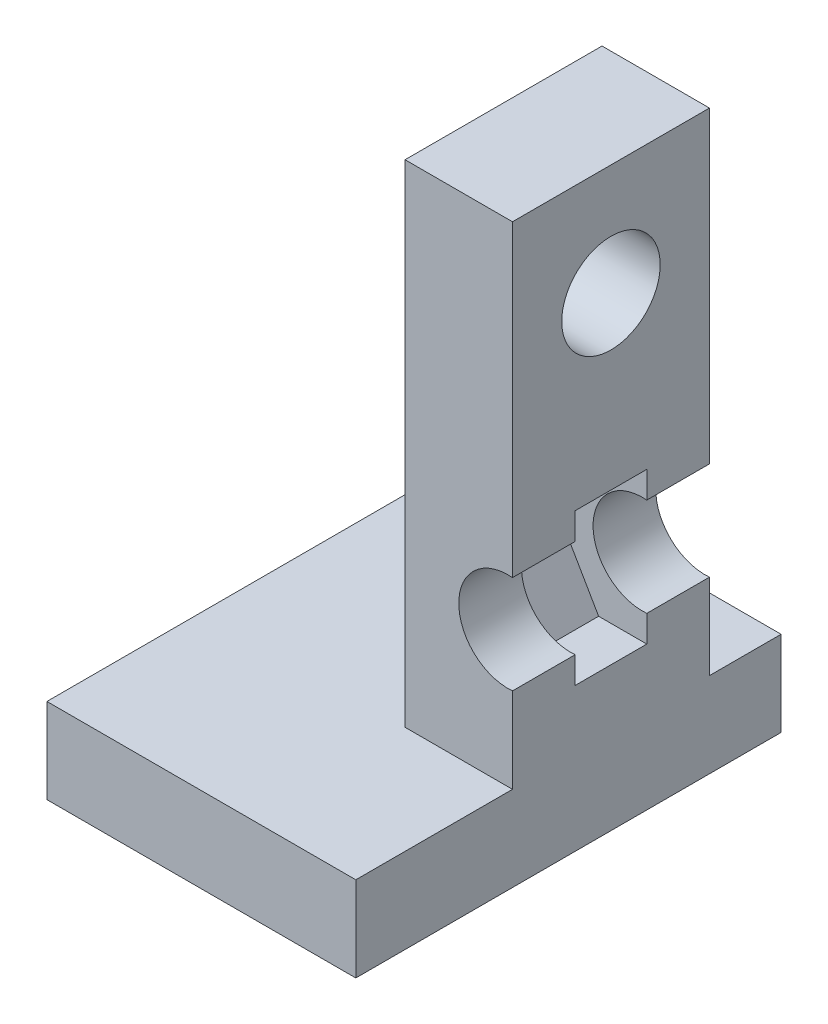
from build123d import *

# Parameters (mm, degrees)
SKETCH_1_W          = 23
SKETCH_1_H          = 64.4
EXTRUDE_1_DEPTH     = 8
SKETCH_3_W          = 23
SKETCH_3_H          = 64.4
SKETCH_3_R          = 5.5
EXTRUDE_2_DEPTH     = 7
SKETCH_4_W          = 23
SKETCH_4_H          = 64.4
SKETCH_4_R          = 5.5
EXTRUDE_3_DEPTH     = 7
SKETCH_5_R          = 5.5
CUT_EXTRUDE_1_DEPTH = 24
SKETCH_6_W          = 22
SKETCH_6_H          = 64.4
CUT_EXTRUDE_2_DEPTH = 11
EXTRUDE_4_DEPTH     = 9.5
SKETCH_9_R          = 5.5
CUT_EXTRUDE_3_DEPTH = 2.5


with BuildPart() as part:
    # 草圖1 → 填料-伸長1 (new body)
    with BuildSketch(Plane.XY):
        with Locations((-0.36746988, -27.579314659)):
            Rectangle(SKETCH_1_W, SKETCH_1_H)
        Polygon((9.38974967, -35.279314659), (4.511139895, -26.829314659), (-5.246079654, -26.829314659), (-10.124689429, -35.279314659), (-5.246079654, -43.729314659), (4.511139895, -43.729314659), align=None, mode=Mode.SUBTRACT)
    extrude(amount=EXTRUDE_1_DEPTH)

    # 草圖3 → 填料-伸長2 (add)
    with BuildSketch(Plane.XY.offset(8)):
        with Locations((-0.36746988, -27.579314659)):
            Rectangle(SKETCH_3_W, SKETCH_3_H)
        with Locations((-0.36746988, -35.279314659)):
            Circle(SKETCH_3_R, mode=Mode.SUBTRACT)
    extrude(amount=EXTRUDE_2_DEPTH)

    # 草圖4 → 填料-伸長3 (add)
    with BuildSketch(Plane(origin=(0, 0, 0), x_dir=(-1, 0, 0), z_dir=(0, 0, -1))):
        with Locations((0.36746988, -27.579314659)):
            Rectangle(SKETCH_4_W, SKETCH_4_H)
        with Locations((0.36746988, -35.279314659)):
            Circle(SKETCH_4_R, mode=Mode.SUBTRACT)
    extrude(amount=EXTRUDE_3_DEPTH)

    # 草圖5 → 除料-伸長1 (cut, through all)
    with BuildSketch(Plane(origin=(11.13253012, 0, 0), x_dir=(0, 0, -1), z_dir=(1, 0, 0))):
        with Locations((-4, -7.779314659)):
            Circle(SKETCH_5_R)
    extrude(amount=-CUT_EXTRUDE_1_DEPTH, mode=Mode.SUBTRACT)

    # 草圖6 → 除料-伸長2 (cut)
    with BuildSketch(Plane(origin=(11.13253012, 0, 0), x_dir=(0, 0, -1), z_dir=(1, 0, 0))):
        with Locations((-4, -27.579314659)):
            Rectangle(SKETCH_6_W, SKETCH_6_H)
    extrude(amount=-CUT_EXTRUDE_2_DEPTH, mode=Mode.SUBTRACT)

    # 草圖8 → 填料-伸長4 (add)
    with BuildSketch(Plane.XZ.offset(59.779314659)):
        Polygon((0.13253012, -7), (0.13253012, -15), (-34.36746988, -15), (-34.36746988, 32.5), (0.13253012, 32.5), align=None)
    extrude(amount=-EXTRUDE_4_DEPTH)

    # 草圖9 → 除料-伸長3 (cut)
    with BuildSketch(Plane.XZ.offset(59.779314659)):
        with Locations((-19.86746988, -3.5)):
            Circle(SKETCH_9_R)
    extrude(amount=-CUT_EXTRUDE_3_DEPTH, mode=Mode.SUBTRACT)


solid = part.part
